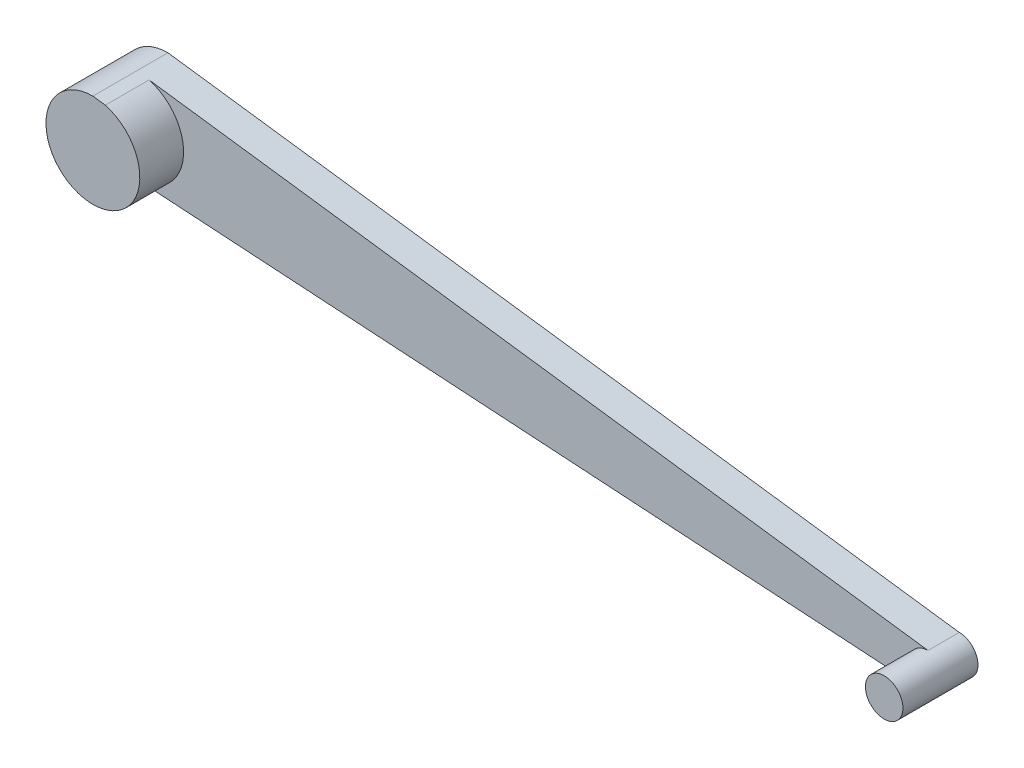
from build123d import *

# Parameters (mm, degrees)
SALIENTE_EXTRUIR1_DEPTH   = 2.4
SALIENTE_EXTRUIR1_2_DEPTH = 2.4
SALIENTE_EXTRUIR2_DEPTH   = 1


with BuildPart() as part:
    # Croquis1 → Saliente-Extruir1 (new body)
    with BuildSketch(Plane.XY):
        with BuildLine():
            Line((-24.903989872, 3.946781248), (-25.3, 4))
            ThreePointArc((-25.3, 4), (-25.499785045, 1.013364222), (-24.903989872, 3.946781248))
        make_face()
    extrude(amount=SALIENTE_EXTRUIR1_DEPTH)



with BuildPart() as body_2:
    # Croquis1 → Saliente-Extruir1 2 (new body)
    with BuildSketch(Plane.XY):
        with BuildLine():
            ThreePointArc((0, -0.6), (0.037869012, 0.598803756), (-0.075587022, -0.595219793))
            Line((-0.075587022, -0.595219793), (0, -0.6))
        make_face()
    extrude(amount=SALIENTE_EXTRUIR1_2_DEPTH)


with BuildPart() as part_1:
    add(part.part)

    add(body_2.part)  # Saliente-Extruir2 merges body 2
    # Croquis1_3 → Saliente-Extruir2 (add)
    with BuildSketch(Plane.XY):
        with BuildLine():
            Line((0, 0.6), (-24.903989872, 3.946781248))
            ThreePointArc((-24.903989872, 3.946781248), (-24.1075204, 3.409940879), (-23.8, 2.5))
            ThreePointArc((-23.8, 2.5), (-24.239339828, 1.439339828), (-25.3, 1))
            Line((-25.3, 1), (-0.075587022, -0.595219793))
            ThreePointArc((-0.075587022, -0.595219793), (-0.598803756, 0.037869012), (0, 0.6))
        make_face()
    extrude(amount=SALIENTE_EXTRUIR2_DEPTH)


solid = part_1.part
